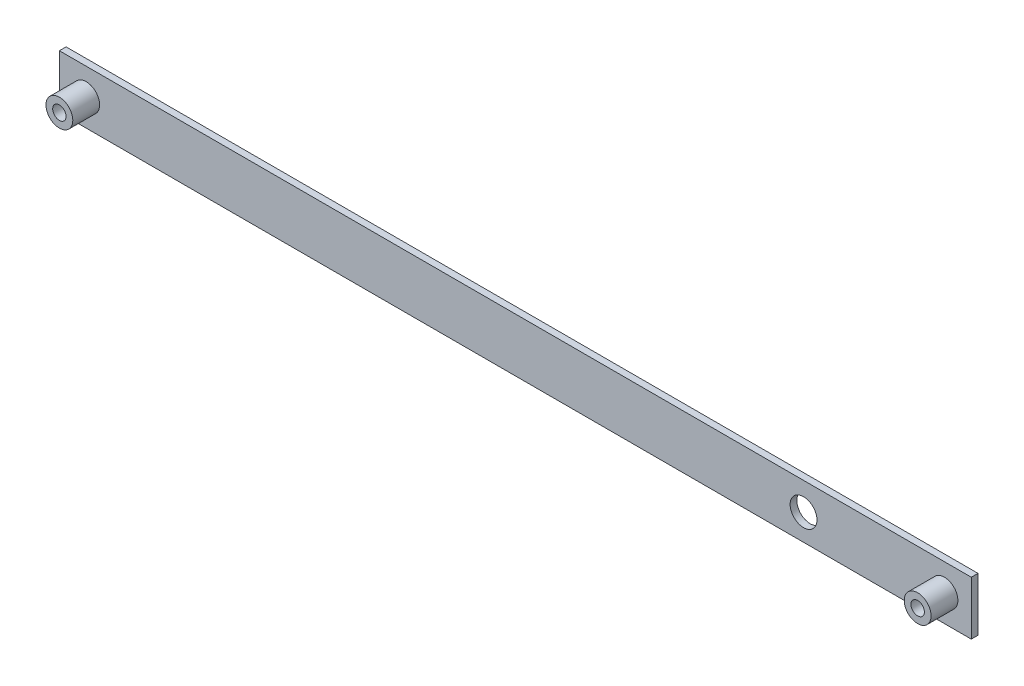
from build123d import *

# Parameters (mm, degrees)
SKETCH1_W           = 431.8
SKETCH1_H           = 25.4
SKETCH1_R           = 3.175
BOSS_EXTRUDE1_DEPTH = 3.175
SKETCH2_R           = 6.35
SKETCH2_R_2         = 3.175
BOSS_EXTRUDE2_DEPTH = 12.7
CUT_EXTRUDE1_REACH  = 5.175
SKETCH3_R           = 6.35


with BuildPart() as part:
    # Sketch1 → Boss-Extrude1 (new body)
    with BuildSketch(Plane.XY):
        with Locations((203.2, 0)):
            Rectangle(SKETCH1_W, SKETCH1_H)
        Circle(SKETCH1_R, mode=Mode.SUBTRACT)
        with Locations((406.4, 0)):
            Circle(SKETCH1_R, mode=Mode.SUBTRACT)
    extrude(amount=BOSS_EXTRUDE1_DEPTH)

    # Sketch2 → Boss-Extrude2 (add)
    with BuildSketch(Plane.XY.offset(3.175)):
        Circle(SKETCH2_R)
        Circle(SKETCH2_R_2, mode=Mode.SUBTRACT)
        with Locations((406.4, 0)):
            Circle(SKETCH2_R)
        with Locations((406.4, 0)):
            Circle(SKETCH2_R_2, mode=Mode.SUBTRACT)
    extrude(amount=BOSS_EXTRUDE2_DEPTH)

    # Sketch3 → Cut-Extrude1 (cut, up to next)
    with BuildSketch(Plane.XY.offset(3.175), mode=Mode.PRIVATE) as cut_extrude1_sk1:
        with Locations((339.668299959, -0.339967612)):
            Circle(SKETCH3_R)
    cut_extrude1_tool1 = extrude(cut_extrude1_sk1.sketch, amount=-CUT_EXTRUDE1_REACH, mode=Mode.PRIVATE) & part.part
    add(cut_extrude1_tool1.solids().sort_by_distance((339.6683, -0.339968, 3.175))[0], mode=Mode.SUBTRACT)


solid = part.part
